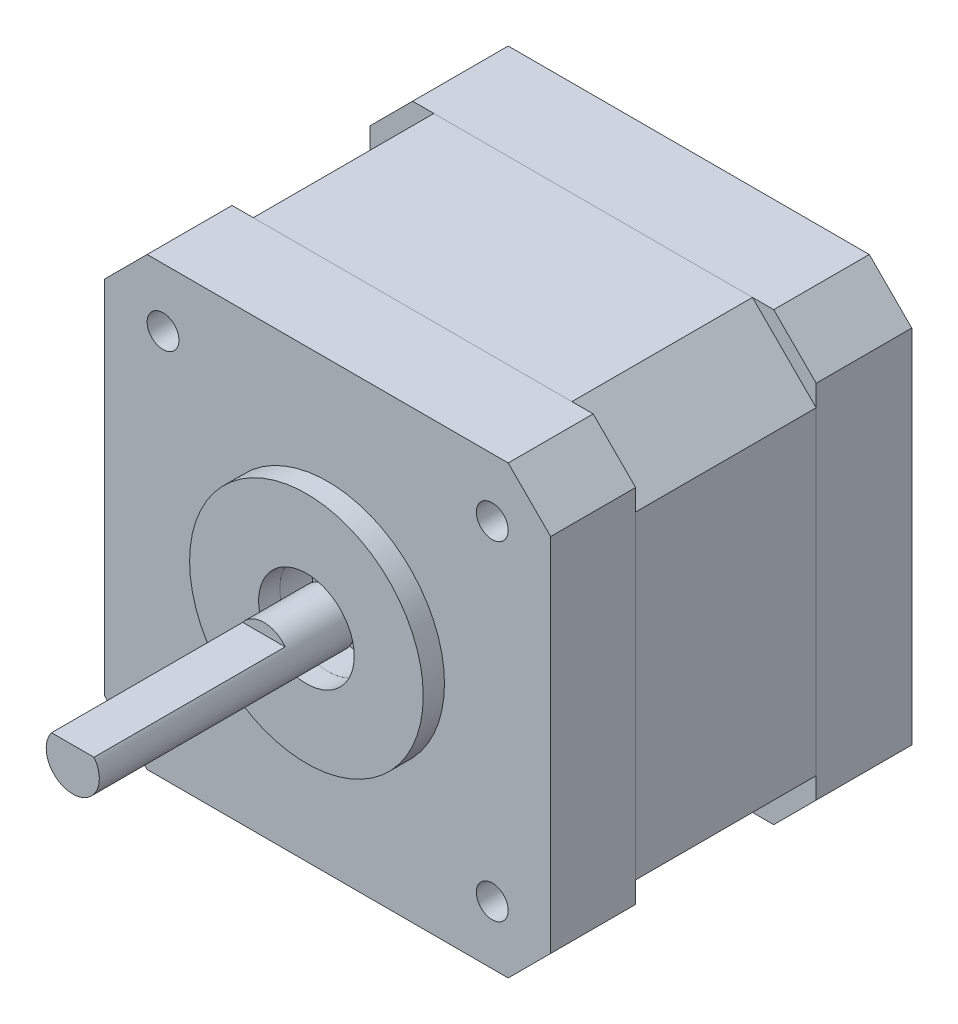
from build123d import *

# Parameters (mm, degrees)
SKETCH_1_W               = 42
SKETCH_1_H               = 42
EXTRUDE_1_DEPTH          = 8.5
CHAMFER_1_SIZE           = 6
SKETCH_15_W              = 42
SKETCH_15_H              = 42
EXTRUDE_11_DEPTH         = 8
SKETCH_16_W              = 42
SKETCH_16_H              = 42
EXTRUDE_12_DEPTH         = 9
CHAMFER_2_SIZE           = 4
CHAMFER_3_SIZE           = 4
SKETCH_2_R               = 11
EXTRUDE_2_DEPTH          = 2
SKETCH_3_R               = 4.5
CUT_EXTRUDE_1_DEPTH      = 5
SKETCH_6_R               = 2.5
EXTRUDE_9_DEPTH          = 24
SKETCH_8_R               = 1.5
CUT_EXTRUDE_3_DEPTH      = 4.5
CUT_EXTRUDE_4_DEPTH      = 18
PATTERN_CIRCULAR_1_COUNT = 4


with BuildPart() as part:
    # 草圖1 → 填料-伸長1 (new body, symmetric)
    with BuildSketch(Plane.XY):
        Rectangle(SKETCH_1_W, SKETCH_1_H)
    extrude(amount=EXTRUDE_1_DEPTH, both=True)

    # 導角1
    chamfer_1_edges = [part.edges().sort_by_distance(p)[0] for p in [
        (21, -21, 0),
        (-21, -21, 0),
        (-21, 21, 0),
        (21, 21, 0),
    ]]
    chamfer(chamfer_1_edges, length=CHAMFER_1_SIZE)


with BuildPart() as body_2:
    # 草圖15 → 填料-伸長11 (new body)
    with BuildSketch(Plane.XY.offset(8.5)):
        Rectangle(SKETCH_15_W, SKETCH_15_H)
    extrude(amount=EXTRUDE_11_DEPTH)

    # 導角2
    chamfer_2_edges = [body_2.edges().sort_by_distance(p)[0] for p in [
        (21, -21, 12.5),
        (-21, -21, 12.5),
        (-21, 21, 12.5),
        (21, 21, 12.5),
    ]]
    chamfer(chamfer_2_edges, length=CHAMFER_2_SIZE)


with BuildPart() as body_3:
    # 草圖16 → 填料-伸長12 (new body)
    with BuildSketch(Plane(origin=(0, 0, -8.5), x_dir=(-1, 0, 0), z_dir=(0, 0, -1))):
        Rectangle(SKETCH_16_W, SKETCH_16_H)
    extrude(amount=EXTRUDE_12_DEPTH)

    # 導角3
    chamfer_3_edges = [body_3.edges().sort_by_distance(p)[0] for p in [
        (-21, -21, -13),
        (21, -21, -13),
        (21, 21, -13),
        (-21, 21, -13),
    ]]
    chamfer(chamfer_3_edges, length=CHAMFER_3_SIZE)


with BuildPart() as body_4:
    # 草圖2 → 填料-伸長2 (new body)
    with BuildSketch(Plane.XY.offset(16.5)):
        Circle(SKETCH_2_R)
    extrude(amount=EXTRUDE_2_DEPTH)


with BuildPart() as cut_extrude_1_tool:
    # 草圖3 → 除料-伸長1 (new body)
    with BuildSketch(Plane.XY.offset(18.5)):
        Circle(SKETCH_3_R)
    extrude(amount=-CUT_EXTRUDE_1_DEPTH)


with BuildPart() as body_2_1:
    add(body_2.part)

    # 除料-伸長1: cut by cut_extrude_1_tool
    add(cut_extrude_1_tool.part, mode=Mode.SUBTRACT)

    # 草圖8 → 除料-伸長3 (cut)
    with BuildSketch(Plane.XY.offset(16.5)):
        with Locations((-15.5, 15.5)):
            Circle(SKETCH_8_R)
    cut_extrude_3 = extrude(amount=-CUT_EXTRUDE_3_DEPTH, mode=Mode.SUBTRACT)

    # 環狀複製排列1: 除料-伸長3 ×4 about axis
    pattern_circular_1_axis = Axis((0, 0, 0), (0, 0, 1))
    for i in range(1, PATTERN_CIRCULAR_1_COUNT):
        add(cut_extrude_3.rotate(pattern_circular_1_axis, i * 360 / PATTERN_CIRCULAR_1_COUNT), mode=Mode.SUBTRACT)


with BuildPart() as body_4_1:
    add(body_4.part)

    # 除料-伸長1: cut by cut_extrude_1_tool
    add(cut_extrude_1_tool.part, mode=Mode.SUBTRACT)


with BuildPart() as body_5:
    # 草圖6 → 填料-伸長9 (new body)
    with BuildSketch(Plane.XY.offset(16.5)):
        Circle(SKETCH_6_R)
    extrude(amount=EXTRUDE_9_DEPTH)

    # 草圖11 → 除料-伸長4 (cut)
    with BuildSketch(Plane.XY.offset(40.5)):
        with BuildLine():
            Line((-2, 1.5), (2, 1.5))
            ThreePointArc((2, 1.5), (0, 2.5), (-2, 1.5))
        make_face()
    extrude(amount=-CUT_EXTRUDE_4_DEPTH, mode=Mode.SUBTRACT)


solid = Compound([part.part, body_3.part, body_2_1.part, body_4_1.part, body_5.part])
